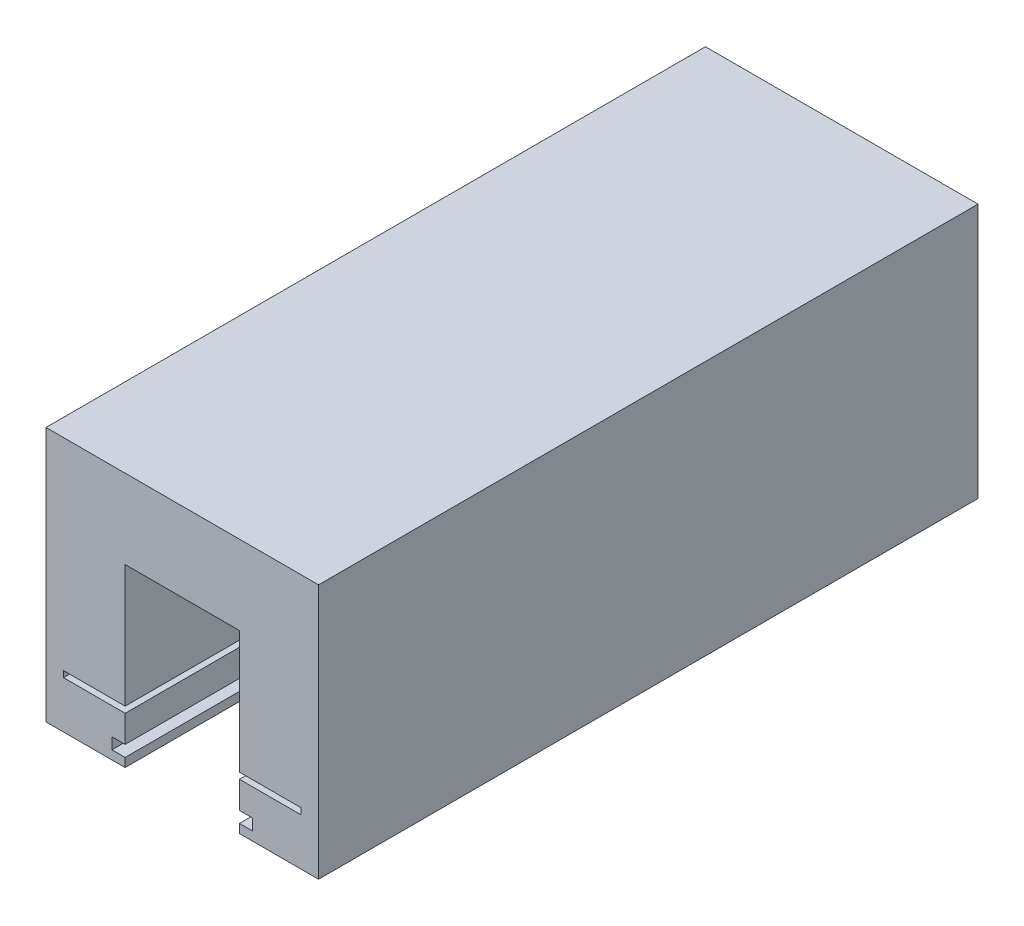
from build123d import *

# Parameters (mm, degrees)
BOSS_EXTRUDE2_DEPTH = 75


with BuildPart() as part:
    # Sketch1 → Boss-Extrude2 (new body)
    with BuildSketch(Plane.XY):
        Polygon((-31, 29), (-31, 0), (-22, 0), (-22, 1), (-23.5, 1), (-23.5, 2.28), (-22, 2.28), (-22, 5.35), (-29, 5.35), (-29, 6.05), (-22, 6.05), (-22, 20), (-9, 20), (-9, 6.05), (-2, 6.05), (-2, 5.35), (-9, 5.35), (-9, 2.28), (-7.5, 2.28), (-7.5, 1), (-9, 1), (-9, 0), (0, 0), (0, 29), align=None)
    extrude(amount=BOSS_EXTRUDE2_DEPTH)


solid = part.part
